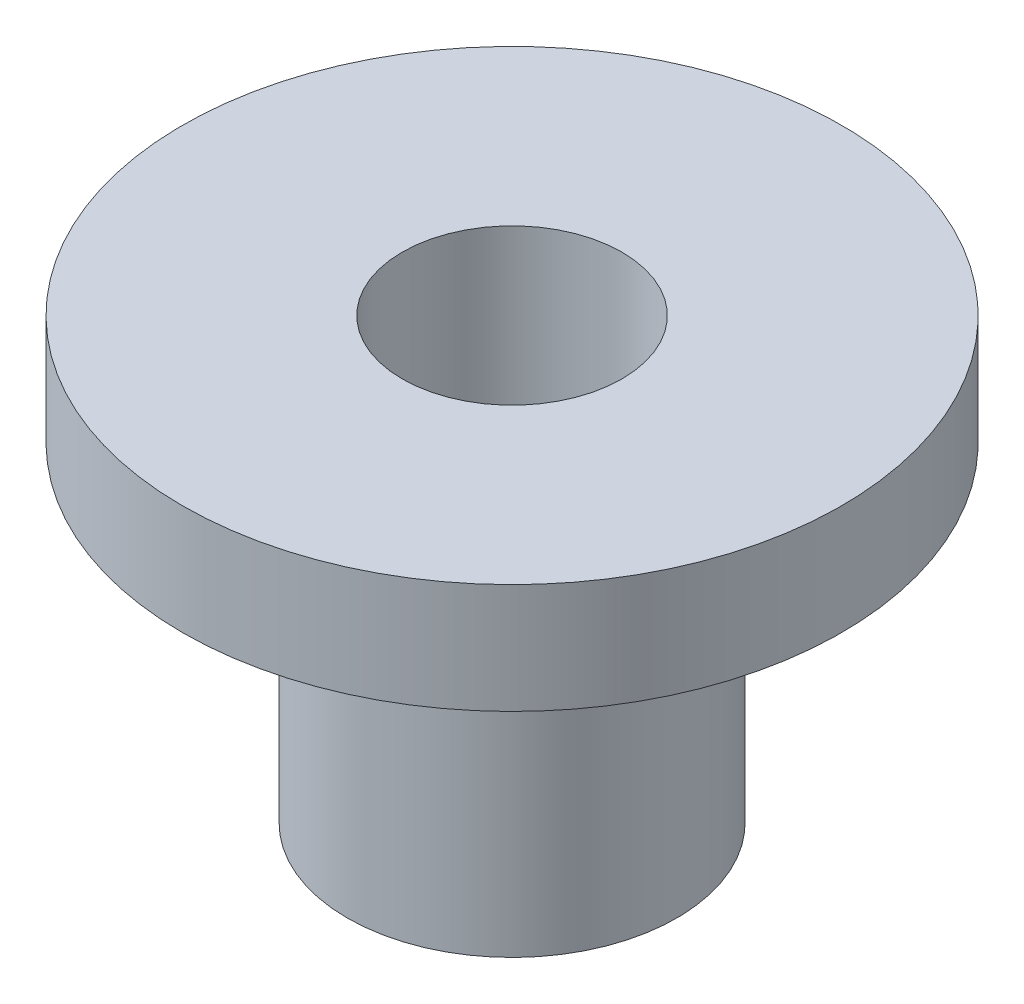
from build123d import *


with BuildPart() as part:
    # Sketch1 → Revolve1 (revolve)
    with BuildSketch(Plane.XY):
        Polygon((-9.525, 0), (-3.175, 0), (-3.175, -12.7), (-4.7625, -12.7), (-4.7625, -3.175), (-9.525, -3.175), align=None)
    revolve(axis=Axis((0, 0, 0), (0, -1, 0)))


solid = part.part
